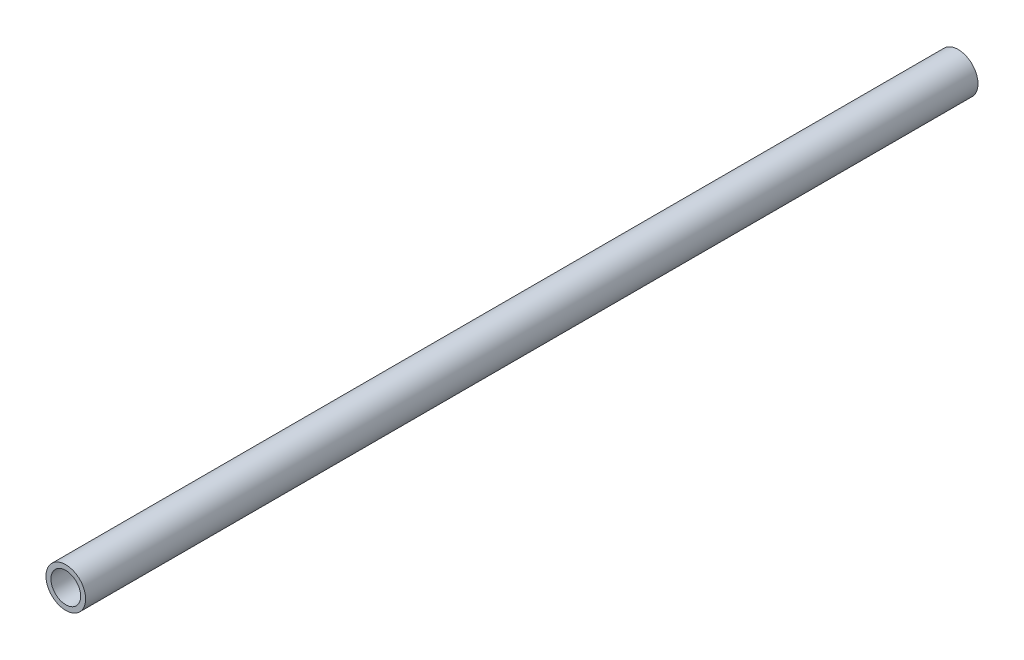
from build123d import *

# Parameters (mm, degrees)
SKETCH_1_R      = 4
SKETCH_1_R_2    = 3
EXTRUDE_1_DEPTH = 180


with BuildPart() as part:
    # 草图1 → 凸台-拉伸1 (new body)
    with BuildSketch(Plane.XY):
        Circle(SKETCH_1_R)
        Circle(SKETCH_1_R_2, mode=Mode.SUBTRACT)
    extrude(amount=EXTRUDE_1_DEPTH)


solid = part.part
